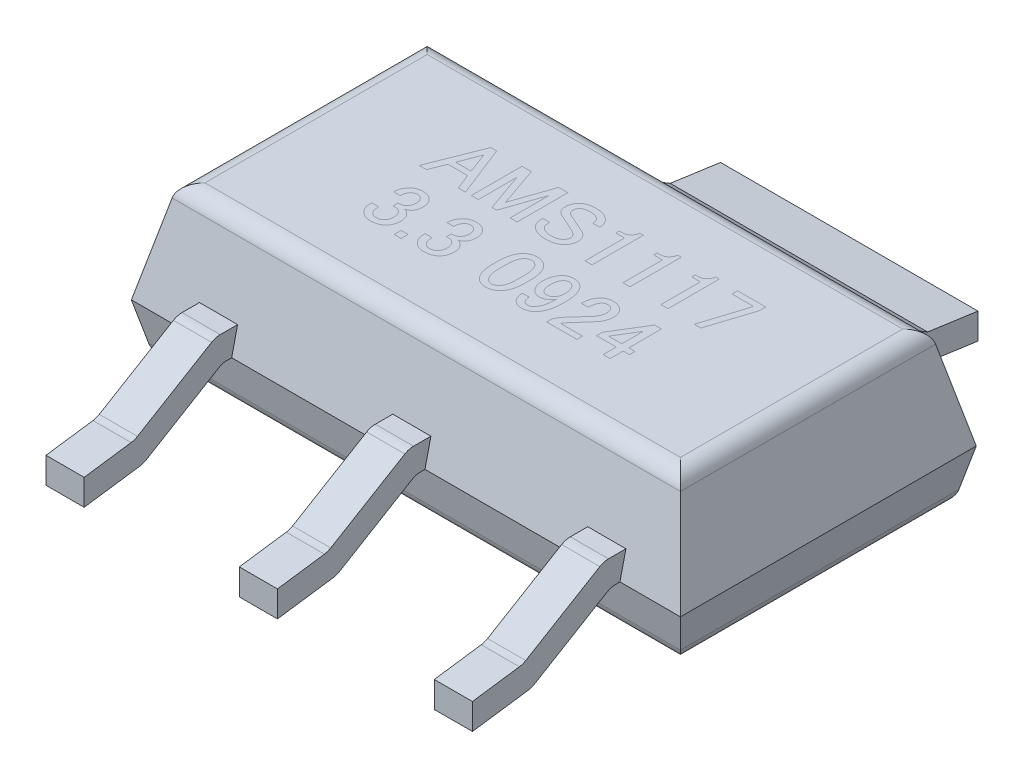
from build123d import *

# Parameters (mm, degrees)
SKETCH5_W           = 6.505
SKETCH5_H           = 3.505
BOSS_EXTRUDE1_DEPTH = 1.2
BOSS_EXTRUDE1_TAPER = 13
SKETCH5_2_W         = 6.505
SKETCH5_2_H         = 3.505
BOSS_EXTRUDE2_DEPTH = 0.6
BOSS_EXTRUDE2_TAPER = 13
BOSS_EXTRUDE3_DEPTH = 0.226
BOSS_EXTRUDE4_DEPTH = 1.525
BOSS_EXTRUDE5_DEPTH = 0.226
BOSS_EXTRUDE6_DEPTH = 0.226
FILLET1_R           = 0.2
FILLET2_R           = 0.2


with BuildPart() as part:
    # Sketch5 → Boss-Extrude1 (new body)
    with BuildSketch(Plane(origin=(0, 0, 0), x_dir=(1, 0, 0), z_dir=(0, 1, 0))):
        Rectangle(SKETCH5_W, SKETCH5_H)
    extrude(amount=BOSS_EXTRUDE1_DEPTH, taper=BOSS_EXTRUDE1_TAPER)

    # Sketch5_2 → Boss-Extrude2 (add)
    with BuildSketch(Plane(origin=(0, 0, 0), x_dir=(1, 0, 0), z_dir=(0, 1, 0))):
        Rectangle(SKETCH5_2_W, SKETCH5_2_H)
    extrude(amount=-BOSS_EXTRUDE2_DEPTH, taper=BOSS_EXTRUDE2_TAPER)

    # Sketch6 → Boss-Extrude3 (add, symmetric)
    with BuildSketch(Plane(origin=(0, 0, 0), x_dir=(0, 0, -1), z_dir=(1, 0, 0))):
        Polygon((-2.903570514, -0.269279893), (-3.5, -0.35310259), (-3.5, -0.6611), (-2.8, -0.562721416), (-1.859056144, 0), (-1.7525, 0), (-1.682085202, 0.305), (-1.943299372, 0.305), align=None)
    boss_extrude3 = extrude(amount=BOSS_EXTRUDE3_DEPTH, both=True)

    # Mirror1: Boss-Extrude3 across plane
    add(boss_extrude3.mirror(Plane.XY))

    # Sketch7 → Boss-Extrude4 (add, symmetric)
    with BuildSketch(Plane(origin=(0, 0, 0), x_dir=(0, 0, -1), z_dir=(1, 0, 0))):
        Polygon((2.903570514, -0.269279893), (1.943299372, 0.305), (1.682085202, 0.305), (1.7525, 0), (1.859056144, 0), (2.8, -0.562721416), (3.5, -0.6611), (3.5, -0.35310259), align=None)
    extrude(amount=BOSS_EXTRUDE4_DEPTH, both=True)

    # Sketch8 → Boss-Extrude5 (add, symmetric)
    with BuildSketch(Plane.ZY.offset(2.29)):
        Polygon((1.859056144, 0), (2.8, -0.562721416), (3.5, -0.6611), (3.5, -0.35310259), (2.903570514, -0.269279893), (1.943299372, 0.305), (1.682085202, 0.305), (1.7525, 0), align=None)
    extrude(amount=BOSS_EXTRUDE5_DEPTH, both=True)

    # Sketch9 → Boss-Extrude6 (add, symmetric)
    with BuildSketch(Plane(origin=(2.31, 0, 0), x_dir=(0, 0, -1), z_dir=(1, 0, 0))):
        Polygon((-2.8, -0.562721416), (-1.859056144, 0), (-1.7525, 0), (-1.682085202, 0.305), (-1.943299372, 0.305), (-2.903570514, -0.269279893), (-3.5, -0.35310259), (-3.5, -0.6611), align=None)
    extrude(amount=BOSS_EXTRUDE6_DEPTH, both=True)

    # Fillet1
    fillet1_edges = [part.edges().sort_by_distance(p)[0] for p in [
        (-2.975458171, 1.2, 0),
        (0, 1.2, 1.475458171),
        (3.113979085, -0.6, 0),
        (0, -0.6, 1.613979085),
        (-3.113979085, -0.6, 0),
        (0, -0.6, -1.613979085),
        (2.975458171, 1.2, 0),
        (0, 1.2, -1.475458171),
    ]]
    fillet(fillet1_edges, radius=FILLET1_R)

    # Fillet2
    fillet2_edges = [part.edges().sort_by_distance(p)[0] for p in [
        (0, -0.562721416, -2.8),
        (0, 0, -1.859056144),
        (-2.29, -0.562721416, 2.8),
        (-2.29, 0, 1.859056144),
        (0, -0.562721416, 2.8),
        (0, 0, 1.859056144),
        (2.31, -0.562721416, 2.8),
        (2.31, 0, 1.859056144),
        (-2.29, 0.305, 1.943299372),
        (-2.29, -0.269279893, 2.903570514),
        (0, 0.305, 1.943299372),
        (0, -0.269279893, 2.903570514),
        (2.31, -0.269279893, 2.903570514),
        (2.31, 0.305, 1.943299372),
    ]]
    fillet(fillet2_edges, radius=FILLET2_R)


solid = part.part
